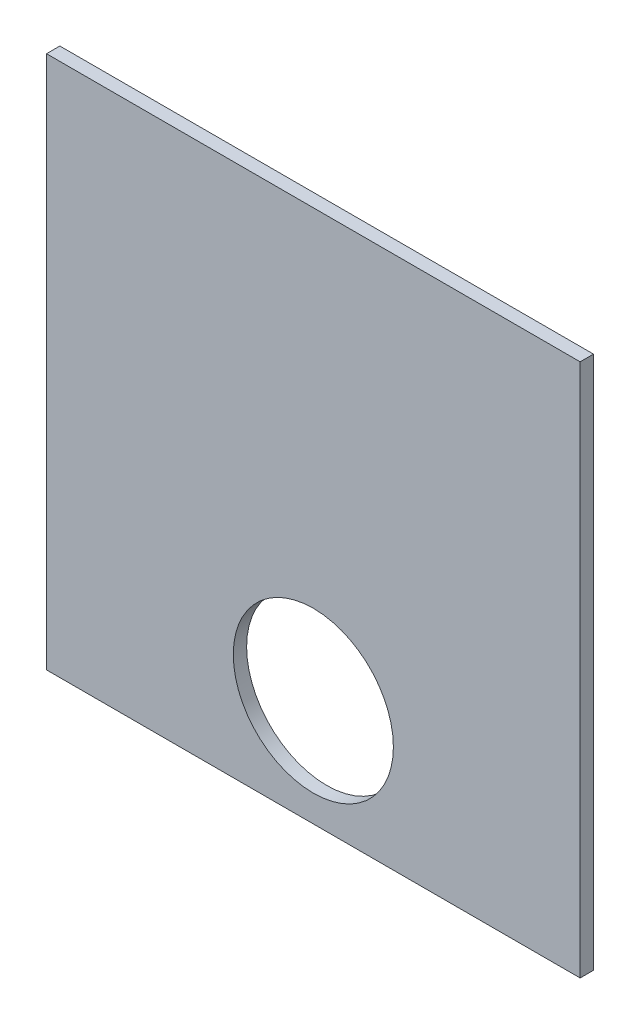
from build123d import *

# Parameters (mm, degrees)
SKETCH1_W           = 254
SKETCH1_H           = 254
BOSS_EXTRUDE1_DEPTH = 6.35
SKETCH2_R           = 38.1
CUT_EXTRUDE1_DEPTH  = 7.35


with BuildPart() as part:
    # Sketch1 → Boss-Extrude1 (new body)
    with BuildSketch(Plane.XY):
        with Locations((127, 127)):
            Rectangle(SKETCH1_W, SKETCH1_H)
    extrude(amount=BOSS_EXTRUDE1_DEPTH)

    # Sketch2 → Cut-Extrude1 (cut, through all)
    with BuildSketch(Plane.XY.offset(6.35)):
        with Locations((127, 50.8)):
            Circle(SKETCH2_R)
    extrude(amount=-CUT_EXTRUDE1_DEPTH, mode=Mode.SUBTRACT)


solid = part.part
